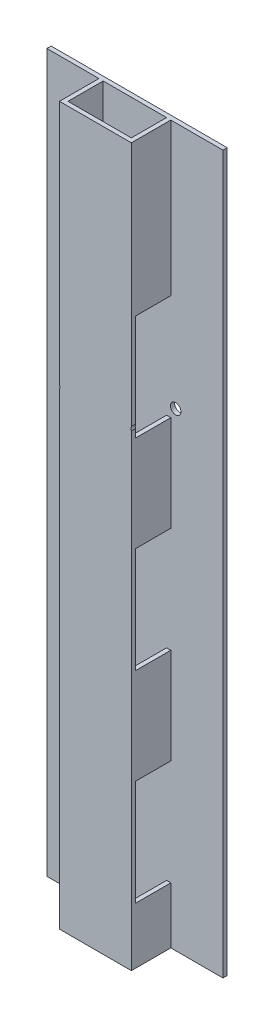
from build123d import *

# Parameters (mm, degrees)
CROQUIS1_W                 = 51
CROQUIS1_H                 = 31
CROQUIS1_W_2               = 45
CROQUIS1_H_2               = 25
SALIENTE_EXTRUIR2_DEPTH    = 254.5
CROQUIS3_W                 = 25
CROQUIS3_H                 = 75
CORTAR_EXTRUIR1_DEPTH      = 1
CORTAR_EXTRUIR1_DEPTH_BACK = 52
CROQUIS4_W                 = 37
CROQUIS4_H                 = 509
SALIENTE_EXTRUIR3_DEPTH    = 3
CORTAR_EXTRUIR2_START      = -4
CROQUIS5_R                 = 3.75
CORTAR_EXTRUIR2_DEPTH      = 33


with BuildPart() as part:
    # Croquis1 → Saliente-Extruir2 (new body, symmetric)
    with BuildSketch(Plane(origin=(0, 0, 0), x_dir=(1, 0, 0), z_dir=(0, 1, 0))):
        Rectangle(CROQUIS1_W, CROQUIS1_H)
        Rectangle(CROQUIS1_W_2, CROQUIS1_H_2, mode=Mode.SUBTRACT)
    extrude(amount=SALIENTE_EXTRUIR2_DEPTH, both=True)

    # Croquis3 → Cortar-Extruir1 (cut, two sides)
    with BuildSketch(Plane(origin=(25.5, 0, 0), x_dir=(0, 0, -1), z_dir=(1, 0, 0))) as cortar_extruir1_sk:
        with Locations((0, 109)):
            Rectangle(CROQUIS3_W, CROQUIS3_H)
        with Locations((0, -34)):
            Rectangle(CROQUIS3_W, CROQUIS3_H)
        with Locations((0, -177)):
            Rectangle(CROQUIS3_W, CROQUIS3_H)
    extrude(amount=CORTAR_EXTRUIR1_DEPTH, mode=Mode.SUBTRACT)
    extrude(cortar_extruir1_sk.sketch, amount=-CORTAR_EXTRUIR1_DEPTH_BACK, mode=Mode.SUBTRACT)

    # Croquis4 → Saliente-Extruir3 (add)
    with BuildSketch(Plane(origin=(0, 0, -15.5), x_dir=(-1, 0, 0), z_dir=(0, 0, -1))):
        with Locations((-44, 0)):
            Rectangle(CROQUIS4_W, CROQUIS4_H)
        with Locations((44, 0)):
            Rectangle(CROQUIS4_W, CROQUIS4_H)
    extrude(amount=-SALIENTE_EXTRUIR3_DEPTH)

    # Croquis5 → Cortar-Extruir2 (cut)
    with BuildSketch(Plane.XY.offset(-12.5).offset(CORTAR_EXTRUIR2_START)):
        with Locations((-29, 78.693747285)):
            Circle(CROQUIS5_R)
    cortar_extruir2 = extrude(amount=CORTAR_EXTRUIR2_DEPTH, mode=Mode.SUBTRACT)

    # Simetría1: Cortar-Extruir2 across plane
    add(cortar_extruir2.mirror(Plane(origin=(0, 0, 0), x_dir=(0, 0, 1), z_dir=(1, 0, 0))), mode=Mode.SUBTRACT)


solid = part.part
